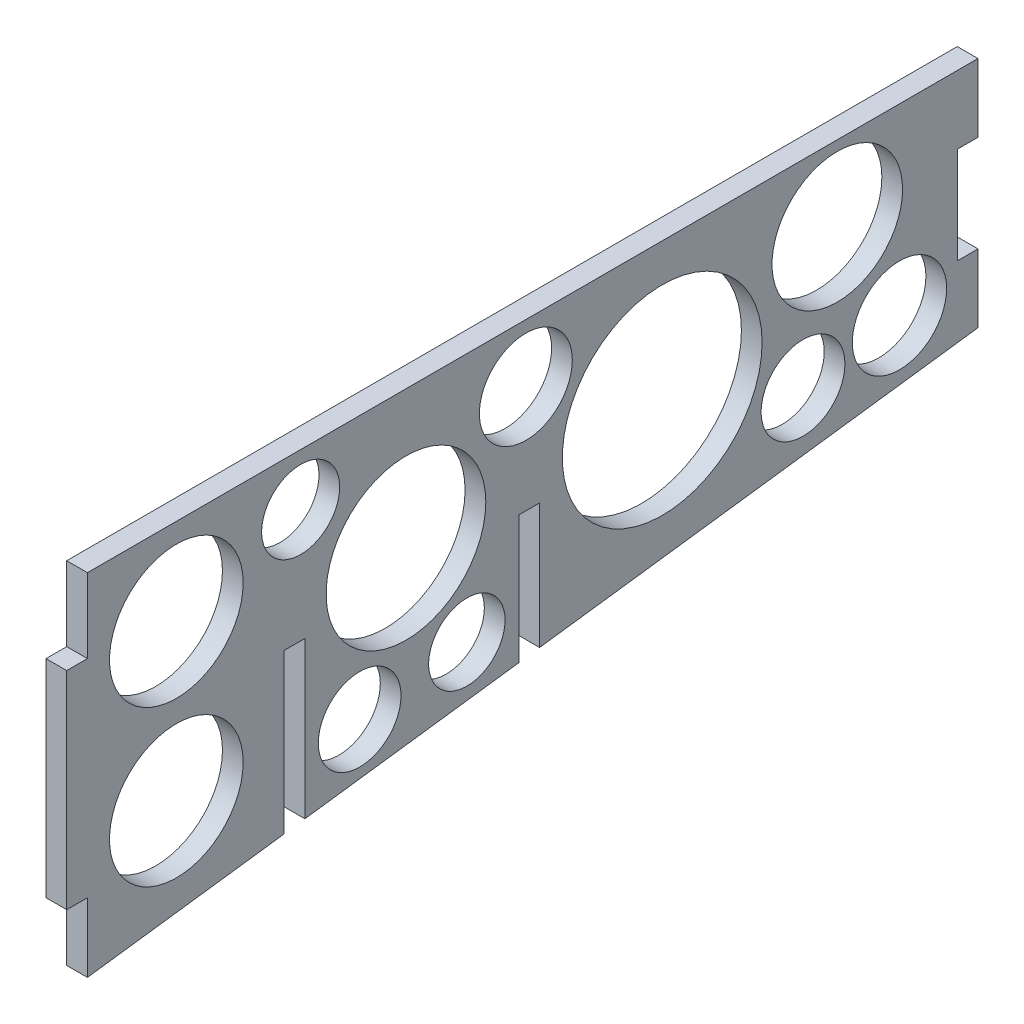
from build123d import *

# Parameters (mm, degrees)
BOSS_EXTRUDE1_DEPTH     = 3
SKETCH2_W               = 3
SKETCH2_H               = 28.023136596
SKETCH2_H_2             = 21.36601765
CUT_EXTRUDE1_DEPTH      = 20
SKETCH3_W               = 3
SKETCH3_H               = 30
BOSS_EXTRUDE2_DEPTH     = 3
SKETCH4_R               = 11.564612176
SKETCH4_R_2             = 9.45507824
SKETCH4_R_3             = 14.470802902
SKETCH4_R_4             = 9.678963713
SKETCH4_R_5             = 5.652740002
SKETCH4_R_6             = 5.531973284
SKETCH4_R_7             = 5.989913263
SKETCH4_R_8             = 6.729308726
SKETCH4_R_9             = 6.066934598
SKETCH4_R_10            = 6.829551901
CUT_EXTRUDE2_DEPTH      = 1
CUT_EXTRUDE2_DEPTH_BACK = 4
SKETCH5_W               = 3
SKETCH5_H               = 14
CUT_EXTRUDE3_DEPTH      = 10


with BuildPart() as part:
    # Sketch1 → Boss-Extrude1 (new body)
    with BuildSketch(Plane(origin=(0, 0, 0), x_dir=(0, 0, -1), z_dir=(1, 0, 0))):
        Polygon((0, 0), (0, -50.777676291), (129, -33.768874681), (129, 0), align=None)
    extrude(amount=BOSS_EXTRUDE1_DEPTH)

    # Sketch2 → Cut-Extrude1 (cut)
    with BuildSketch(Plane(origin=(3, 0, 0), x_dir=(0, 0, -1), z_dir=(1, 0, 0))):
        with Locations((30, -38.011568298)):
            Rectangle(SKETCH2_W, SKETCH2_H)
        with Locations((64, -34.683008825)):
            Rectangle(SKETCH2_W, SKETCH2_H_2)
    extrude(amount=-CUT_EXTRUDE1_DEPTH, mode=Mode.SUBTRACT)

    # Sketch3 → Boss-Extrude2 (add)
    with BuildSketch(Plane(origin=(3, 0, 0), x_dir=(0, 0, -1), z_dir=(1, 0, 0))):
        with Locations((-1.5, -25.777676291)):
            Rectangle(SKETCH3_W, SKETCH3_H)
    extrude(amount=-BOSS_EXTRUDE2_DEPTH)

    # Sketch4 → Cut-Extrude2 (cut, two sides)
    with BuildSketch(Plane(origin=(3, 0, 0), x_dir=(0, 0, -1), z_dir=(1, 0, 0))) as cut_extrude2_sk:
        with Locations((46.139822704, -19.984473783)):
            Circle(SKETCH4_R)
        with Locations((108.618953829, -10.917568804)):
            Circle(SKETCH4_R_2)
        with Locations((83.259777078, -19.984473783)):
            Circle(SKETCH4_R_3)
        with Locations((12.878873487, -12.542106693)):
            Circle(SKETCH4_R_4)
        with Locations((12.878873487, -35.052970113)):
            Circle(SKETCH4_R_4)
        with Locations((30.887564223, -7.517969022)):
            Circle(SKETCH4_R_5)
        with Locations((54.960405921, -36.18486448)):
            Circle(SKETCH4_R_6)
        with Locations((39.432504215, -38.114367059)):
            Circle(SKETCH4_R_7)
        with Locations((63.505345914, -8.436779774)):
            Circle(SKETCH4_R_8)
        with Locations((103.657375769, -28.650616315)):
            Circle(SKETCH4_R_9)
        with Locations((117.623299197, -26.537351586)):
            Circle(SKETCH4_R_10)
    extrude(amount=CUT_EXTRUDE2_DEPTH, mode=Mode.SUBTRACT)
    extrude(cut_extrude2_sk.sketch, amount=-CUT_EXTRUDE2_DEPTH_BACK, mode=Mode.SUBTRACT)

    # Sketch5 → Cut-Extrude3 (cut)
    with BuildSketch(Plane(origin=(3, 0, 0), x_dir=(0, 0, -1), z_dir=(1, 0, 0))):
        with Locations((127.5, -16.88443734)):
            Rectangle(SKETCH5_W, SKETCH5_H)
    extrude(amount=-CUT_EXTRUDE3_DEPTH, mode=Mode.SUBTRACT)


solid = part.part
